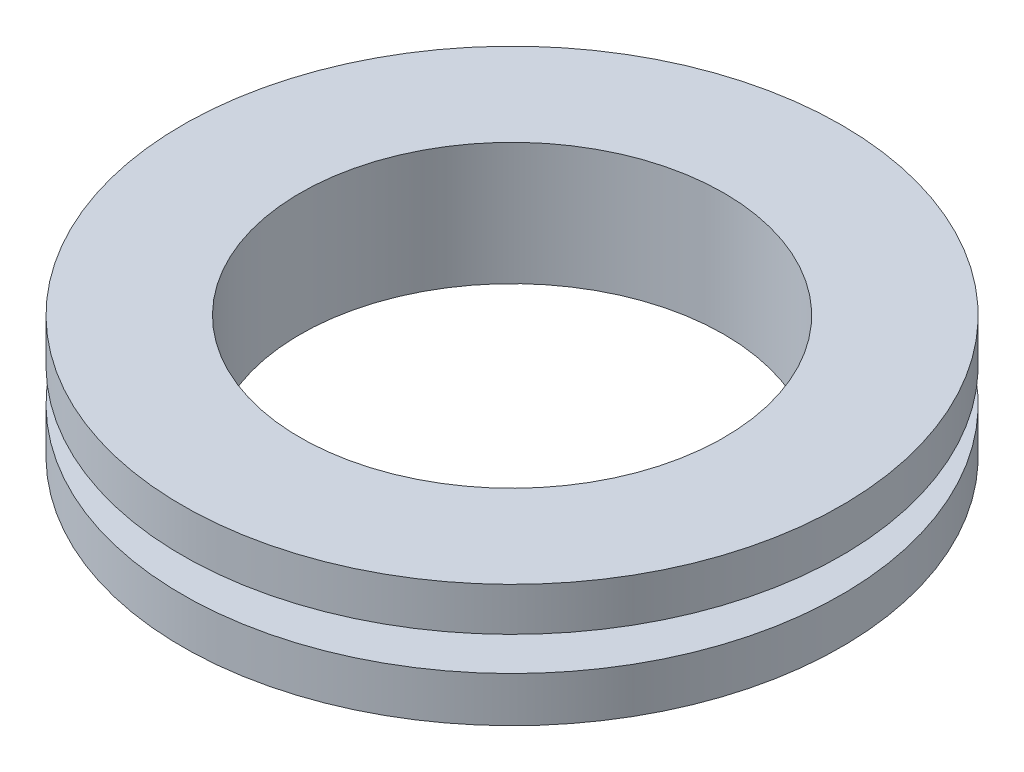
from build123d import *


with BuildPart() as part:
    # Sketch1 → Revolve1 (revolve)
    with BuildSketch(Plane.XY):
        Polygon((17.5, 2.4), (14.75, 2.4), (14.75, 4.2), (17.5, 4.2), (17.5, 6.5), (11.25, 6.5), (11.25, 0), (17.5, 0), align=None)
    revolve(axis=Axis((0, 0, 0), (0, 1, 0)))


solid = part.part
